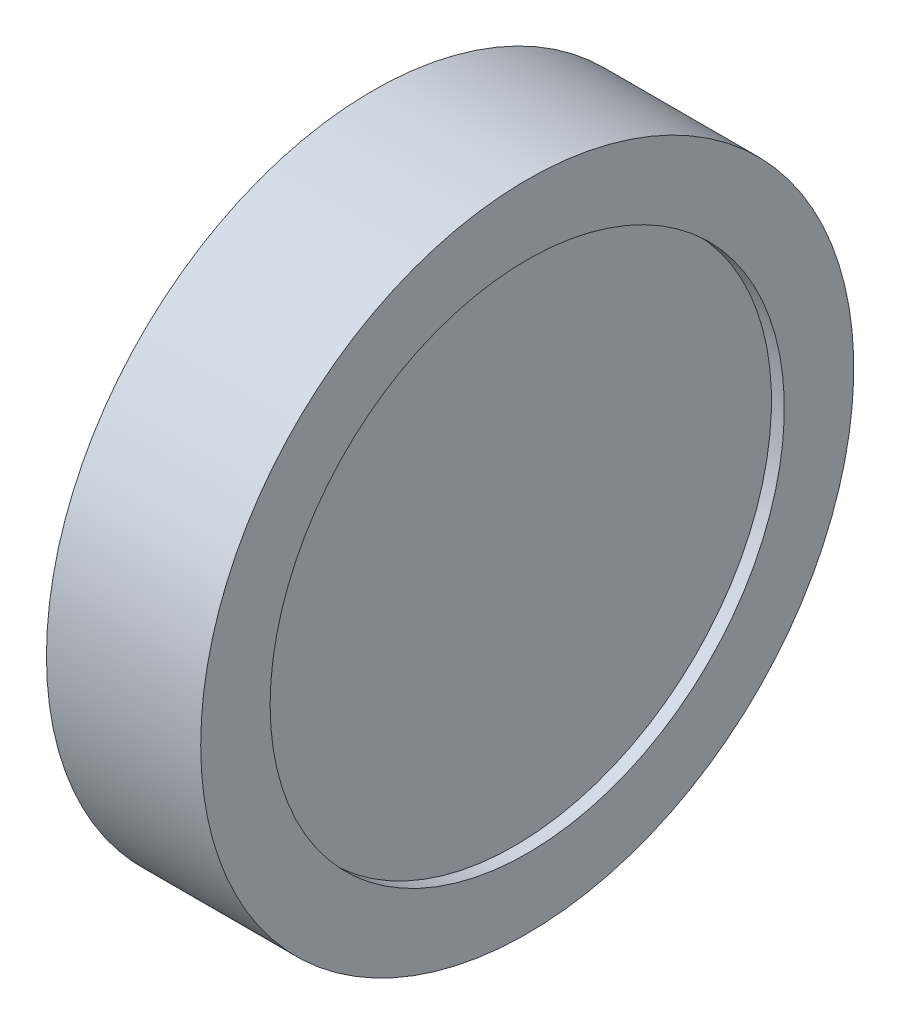
from build123d import *

# Parameters (mm, degrees)
SKETCH_1_W = 5
SKETCH_1_H = 10
SKETCH_4_W = 6
SKETCH_4_H = 2.7


with BuildPart() as part:
    # 草图1 → 旋转2 (revolve)
    with BuildSketch(Plane.XY, mode=Mode.PRIVATE) as revolve_2_sk:
        with Locations((0, 5)):
            Rectangle(SKETCH_1_W, SKETCH_1_H)
    revolve(revolve_2_sk.sketch.rotate(Axis((-2.5, 0, 0), (1, 0, 0)), 90), axis=Axis((-2.5, 0, 0), (1, 0, 0)))  # turned: the seam where the file's is

    # 草图4 → 旋转3 (revolve)
    with BuildSketch(Plane.XY, mode=Mode.PRIVATE) as revolve_3_sk:
        with Locations((0, 11.35)):
            Rectangle(SKETCH_4_W, SKETCH_4_H)
    revolve(revolve_3_sk.sketch.rotate(Axis((-1.614212419, 0, 0), (1, 0, 0)), 90), axis=Axis((-1.614212419, 0, 0), (1, 0, 0)))  # turned: the seam where the file's is


solid = part.part
